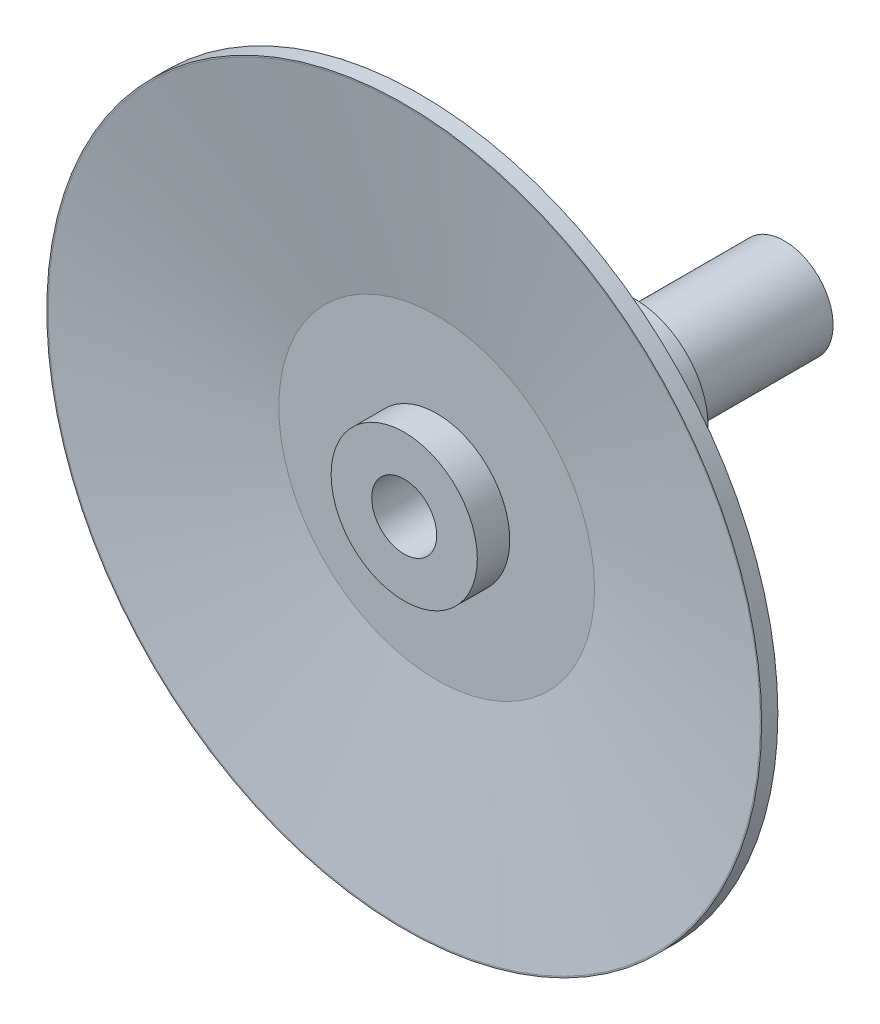
from build123d import *

# Parameters (mm, degrees)
SKETCH1_R           = 22.5
BOSS_EXTRUDE1_DEPTH = 162
SKETCH4_R           = 22.5
SKETCH4_R_2         = 15
CUT_EXTRUDE1_DEPTH  = 91
SKETCH5_R           = 15
CUT_EXTRUDE2_DEPTH  = 45
SKETCH12_R          = 10
CUT_EXTRUDE3_DEPTH  = 118
SKETCH13_W          = 3
SKETCH13_H          = 3
CUT_EXTRUDE4_DEPTH  = 50


with BuildPart() as part:
    # Sketch1 → Boss-Extrude1 (new body)
    with BuildSketch(Plane.XY):
        Circle(SKETCH1_R)
    extrude(amount=BOSS_EXTRUDE1_DEPTH)

    # Sketch3 → Revolve1 (revolve)
    with BuildSketch(Plane(origin=(0, 0, 0), x_dir=(0, 0, -1), z_dir=(1, 0, 0))):
        Polygon((-157, 110), (-162, 110), (-162, 109.592881079), (-152, 48.592881079), (-152, 22.5), (-147, 22.5), (-147, 49), align=None)
    revolve(axis=Axis((0, 0, 162), (0, 0, -1)))

    # Sketch4 → Cut-Extrude1 (cut)
    with BuildSketch(Plane(origin=(0, 0, 0), x_dir=(-1, 0, 0), z_dir=(0, 0, -1))):
        Circle(SKETCH4_R)
        Circle(SKETCH4_R_2, mode=Mode.SUBTRACT)
    extrude(amount=-CUT_EXTRUDE1_DEPTH, mode=Mode.SUBTRACT)

    # Sketch5 → Cut-Extrude2 (cut)
    with BuildSketch(Plane(origin=(0, 0, 0), x_dir=(-1, 0, 0), z_dir=(0, 0, -1))):
        Circle(SKETCH5_R)
    extrude(amount=-CUT_EXTRUDE2_DEPTH, mode=Mode.SUBTRACT)

    # Sketch12 → Cut-Extrude3 (cut, through all)
    with BuildSketch(Plane(origin=(0, 0, 45), x_dir=(-1, 0, 0), z_dir=(0, 0, -1))):
        Circle(SKETCH12_R)
    extrude(amount=-CUT_EXTRUDE3_DEPTH, mode=Mode.SUBTRACT)

    # Sketch13 → Cut-Extrude4 (cut)
    with BuildSketch(Plane(origin=(0, 0, 45), x_dir=(-1, 0, 0), z_dir=(0, 0, -1))):
        with Locations((0, -10)):
            Rectangle(SKETCH13_W, SKETCH13_H)
    extrude(amount=-CUT_EXTRUDE4_DEPTH, mode=Mode.SUBTRACT)


solid = part.part
